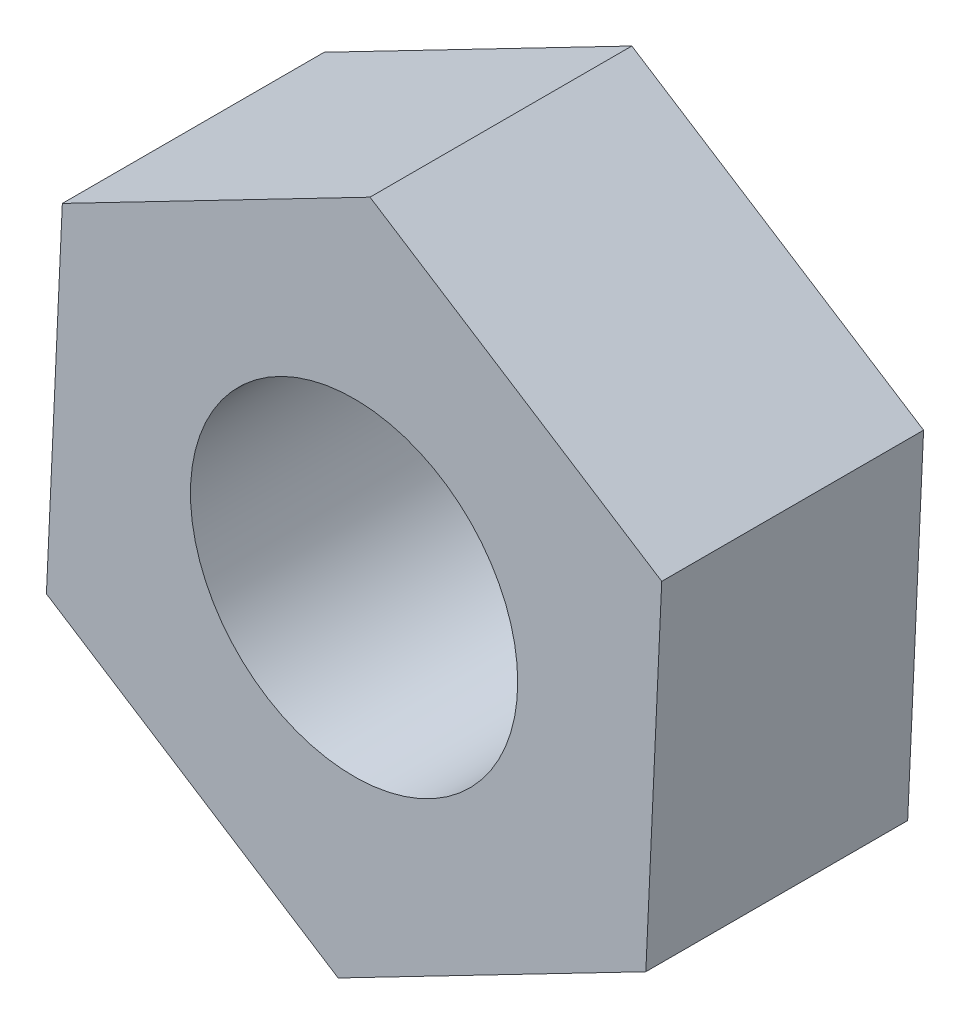
from build123d import *

# Parameters (mm, degrees)
SKETCH_1_R      = 1.5
EXTRUDE_1_DEPTH = 2.4


with BuildPart() as part:
    # ｽｹｯﾁ1 → ﾎﾞｽ - 押し出し1 (new body)
    with BuildSketch(Plane.XY):
        Polygon((-2.820050535, -1.459674044), (-0.145910464, -3.172072425), (2.674140071, -1.712398381), (2.820050535, 1.459674044), (0.145910464, 3.172072425), (-2.674140071, 1.712398381), align=None)
        Circle(SKETCH_1_R, mode=Mode.SUBTRACT)
    extrude(amount=EXTRUDE_1_DEPTH)


solid = part.part
